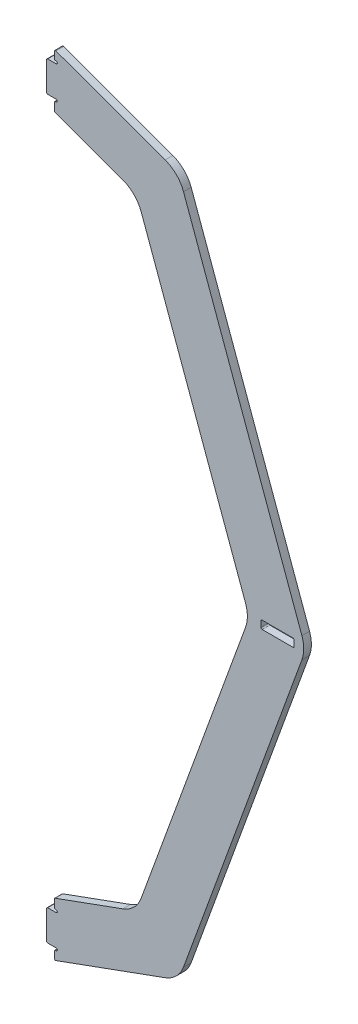
from build123d import *

# Parameters (mm, degrees)
SKETCH1_W           = 13.716
SKETCH1_H           = 3.3528
BOSS_EXTRUDE1_DEPTH = 3.175
FILLET1_R           = 12.7
CUT_EXTRUDE1_DEPTH  = 4.175
FILLET2_R           = 0.508


with BuildPart() as part:
    # Sketch1 → Boss-Extrude1 (new body)
    with BuildSketch(Plane.XY):
        Polygon((114.3, 158.75), (114.3, 146.05), (117.475, 146.05), (117.475, 141.224), (151.477068993, 128.848258983), (198.374, 0), (151.477068993, -128.848258983), (117.475, -141.224), (117.475, -146.05), (114.3, -146.05), (114.3, -158.75), (117.475, -158.75), (117.475, -163.576), (169.035670284, -144.809450758), (221.742, 0), (169.035670284, 144.809450758), (117.475, 163.576), (117.475, 158.75), align=None)
        with Locations((210.058, 0)):
            Rectangle(SKETCH1_W, SKETCH1_H, mode=Mode.SUBTRACT)
    extrude(amount=BOSS_EXTRUDE1_DEPTH)

    # Fillet1
    fillet1_edges = [part.edges().sort_by_distance(p)[0] for p in [
        (169.035670284, 144.809450758, 1.5875),
        (221.742, 0, 1.5875),
        (169.035670284, -144.809450758, 1.5875),
        (151.477068993, -128.848258983, 1.5875),
        (198.374, 0, 1.5875),
        (151.477068993, 128.848258983, 1.5875),
    ]]
    fillet(fillet1_edges, radius=FILLET1_R)

    # Sketch2 → Cut-Extrude1 (cut, through all)
    with BuildSketch(Plane.XY.offset(3.175)):
        with BuildLine():
            Line((117.475, 146.05), (118.237, 146.05))
            ThreePointArc((118.237, 146.05), (118.745, 145.542), (118.237, 145.034))
            Line((118.237, 145.034), (117.475, 145.034))
            Line((117.475, 145.034), (117.475, 146.05))
        make_face()
        with BuildLine():
            Line((117.475, 158.75), (118.237, 158.75))
            ThreePointArc((118.237, 158.75), (118.745, 159.258), (118.237, 159.766))
            Line((118.237, 159.766), (117.475, 159.766))
            Line((117.475, 159.766), (117.475, 158.75))
        make_face()
        with BuildLine():
            Line((117.475, -145.034), (117.475, -146.05))
            Line((117.475, -146.05), (118.237, -146.05))
            ThreePointArc((118.237, -146.05), (118.745, -145.542), (118.237, -145.034))
            Line((118.237, -145.034), (117.475, -145.034))
        make_face()
        with BuildLine():
            Line((117.475, -158.75), (117.475, -159.766))
            Line((117.475, -159.766), (118.237, -159.766))
            ThreePointArc((118.237, -159.766), (118.745, -159.258), (118.237, -158.75))
            Line((118.237, -158.75), (117.475, -158.75))
        make_face()
    extrude(amount=-CUT_EXTRUDE1_DEPTH, mode=Mode.SUBTRACT)

    # Fillet2
    fillet2_edges = [part.edges().sort_by_distance(p)[0] for p in [
        (117.475, 163.576, 1.5875),
        (117.475, -163.576, 1.5875),
        (114.3, -158.75, 1.5875),
        (114.3, -146.05, 1.5875),
        (117.475, -141.224, 1.5875),
        (117.475, 141.224, 1.5875),
        (114.3, 146.05, 1.5875),
        (114.3, 158.75, 1.5875),
        (117.475, 159.766, 1.5875),
        (117.475, -159.766, 1.5875),
        (117.475, -145.034, 1.5875),
        (117.475, 145.034, 1.5875),
        (203.2, 1.6764, 1.5875),
        (203.2, -1.6764, 1.5875),
        (216.916, -1.6764, 1.5875),
        (216.916, 1.6764, 1.5875),
    ]]
    fillet(fillet2_edges, radius=FILLET2_R)


solid = part.part
